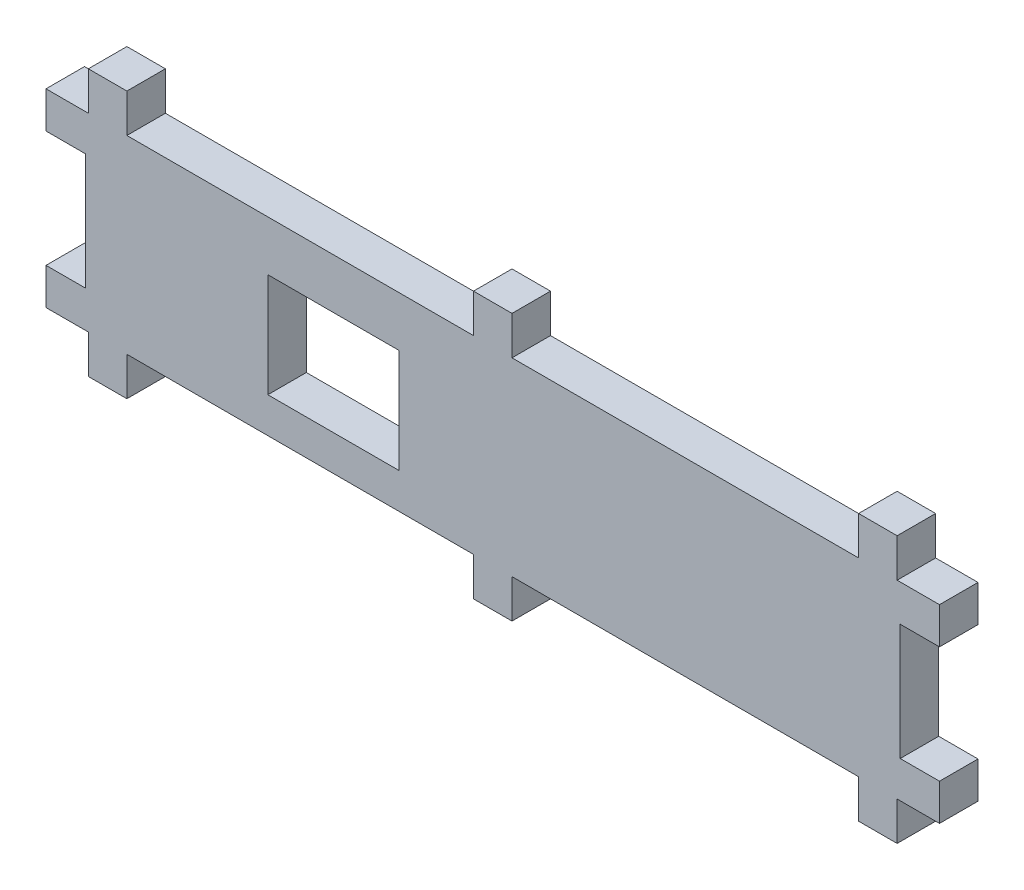
from build123d import *

# Parameters (mm, degrees)
SKETCH1_W           = 116
SKETCH1_H           = 12.3
BOSS_EXTRUDE1_DEPTH = 5
SKETCH2_W           = 5
SKETCH2_H           = 5
BOSS_EXTRUDE2_DEPTH = 5
SKETCH3_W           = 17
SKETCH3_H           = 13.5
CUT_EXTRUDE1_DEPTH  = 6
SKETCH4_W           = 5
SKETCH4_H           = 15.1
CUT_EXTRUDE2_DEPTH  = 5.1


with BuildPart() as part:
    # Sketch1 → Boss-Extrude1 (new body)
    with BuildSketch(Plane.XY):
        Rectangle(SKETCH1_W, SKETCH1_H)
    extrude(amount=BOSS_EXTRUDE1_DEPTH)

    # Sketch2 → Boss-Extrude2 (add)
    with BuildSketch(Plane.XZ.offset(6.15)):
        with Locations((-50, 2.5)):
            Rectangle(SKETCH2_W, SKETCH2_H)
        with Locations((0, 2.5)):
            Rectangle(SKETCH2_W, SKETCH2_H)
        with Locations((50, 2.5)):
            Rectangle(SKETCH2_W, SKETCH2_H)
    extrude(amount=BOSS_EXTRUDE2_DEPTH)

    # Mirror1: part across plane


with BuildPart() as part_1:
    add(part.part)
    add(part.part.mirror(Plane(origin=(-58, 6.15, 5), x_dir=(0, 0, 1), z_dir=(0, -1, 0))))

    # Sketch3 → Cut-Extrude1 (cut, through all)
    with BuildSketch(Plane.XY.offset(5)):
        with Locations((-20.7, 5.2)):
            Rectangle(SKETCH3_W, SKETCH3_H)
    extrude(amount=-CUT_EXTRUDE1_DEPTH, mode=Mode.SUBTRACT)

    # Sketch4 → Cut-Extrude2 (cut)
    with BuildSketch(Plane.ZY.offset(58)):
        with Locations((2.5, 6.15)):
            Rectangle(SKETCH4_W, SKETCH4_H)
    cut_extrude2 = extrude(amount=-CUT_EXTRUDE2_DEPTH, mode=Mode.SUBTRACT)

    # Mirror2: Cut-Extrude2 across plane
    add(cut_extrude2.mirror(Plane(origin=(0, 0, 0), x_dir=(0, 0, 1), z_dir=(1, 0, 0))), mode=Mode.SUBTRACT)


solid = part_1.part
